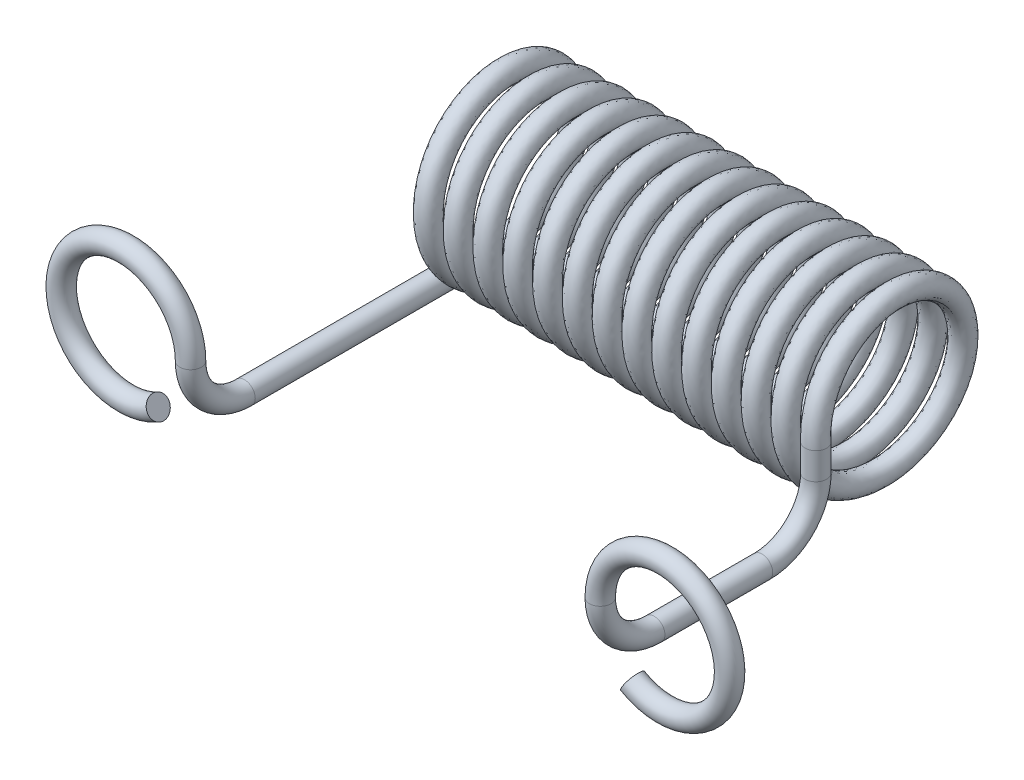
from build123d import *

# Parameters (mm, degrees)
SKETCH20_R          = 0.2
SKETCH23_R          = 0.2
SKETCH27_R          = 0.2
SWEEP16_PITCH       = 0.552727273
SWEEP16_HEIGHT      = 7.6
SWEEP16_RADIUS      = 1.5
SWEEP16_START_ANGLE = 180
SKETCH29_R          = 0.2
SKETCH31_R          = 0.2
BOSS_EXTRUDE4_DEPTH = 4.5
SKETCH32_R          = 0.2


with BuildPart() as part:
    # Sweep8: sweep along a path in Sketch12
    with BuildLine(Plane(origin=(3.8, 0, 0), x_dir=(0, 0, -1), z_dir=(1, 0, 0))) as sweep8_path:
        Line((3, 1.5), (3, 1))
        ThreePointArc((3, 1), (2.707106781, 0.292893219), (2, 0))
        Line((2, 0), (0, 0))
        ThreePointArc((0, 0), (-0.707106781, 0.292893219), (-1, 1))
    # Sketch20 → Sweep8 (sweep)
    with BuildSketch(Plane(origin=(0, 1, 0), x_dir=(1, 0, 0), z_dir=(0, 1, 0))):
        with Locations((3.8, -1)):
            Circle(SKETCH20_R)
    sweep(path=sweep8_path.line)

    # Sweep16: sweep along a helix
    with BuildLine() as sweep16_path:
        add(Helix(SWEEP16_PITCH, SWEEP16_HEIGHT, SWEEP16_RADIUS, center=(3.8, 1.5, -4.5), direction=(-1, 0, 0), mode=Mode.PRIVATE).rotate(Axis((3.8, 1.5, -4.5), (-1, 0, 0)), SWEEP16_START_ANGLE))
    # Sketch29 → Sweep16 (sweep)
    with BuildSketch(Plane(origin=(0, 1.5, 0), x_dir=(1, 0, 0), z_dir=(0, 1, 0))):
        with Locations((3.8, 3)):
            Circle(SKETCH29_R)
    sweep(path=sweep16_path.line, is_frenet=True)

    # Sketch31 → Boss-Extrude4 (add)
    with BuildSketch(Plane.XY.offset(-4.5)):
        with Locations((-3.8, 0)):
            Circle(SKETCH31_R)
    extrude(amount=BOSS_EXTRUDE4_DEPTH)



with BuildPart() as body_2:
    # Sweep10: sweep along a path in Sketch24
    with BuildLine(Plane.XY.offset(1)) as sweep10_path:
        ThreePointArc((-3.8, 1), (-6.039230485, 1.6), (-4.4, -0.039230485))
    # Sketch23 → Sweep10 (sweep)
    with BuildSketch(Plane(origin=(0, 1, 0), x_dir=(1, 0, 0), z_dir=(0, 1, 0))):
        with Locations((-3.8, -1)):
            Circle(SKETCH23_R)
    sweep(path=sweep10_path.line)


with BuildPart() as body_3:
    # Sweep15: sweep along a path in Sketch28
    with BuildLine(Plane.XY.offset(1)) as sweep15_path:
        ThreePointArc((3.8, 1), (6.039230485, 1.6), (4.4, -0.039230485))
    # Sketch27 → Sweep15 (sweep)
    with BuildSketch(Plane(origin=(0, 1, 0), x_dir=(1, 0, 0), z_dir=(0, 1, 0))):
        with Locations((3.8, -1)):
            Circle(SKETCH27_R)
    sweep(path=sweep15_path.line)


with BuildPart() as part_1:
    add(part.part)

    add(body_2.part)  # Sweep17 merges body 2
    # Sweep17: sweep along a path in Sketch21
    with BuildLine(Plane(origin=(-3.8, 0, 0), x_dir=(0, 0, -1), z_dir=(1, 0, 0))) as sweep17_path:
        ThreePointArc((0, 0), (-0.707106781, 0.292893219), (-1, 1))
    # Sketch32 → Sweep17 (sweep)
    with BuildSketch(Plane.XY):
        with Locations((-3.8, 0)):
            Circle(SKETCH32_R)
    sweep(path=sweep17_path.line)


solid = Compound([body_3.part, part_1.part])
